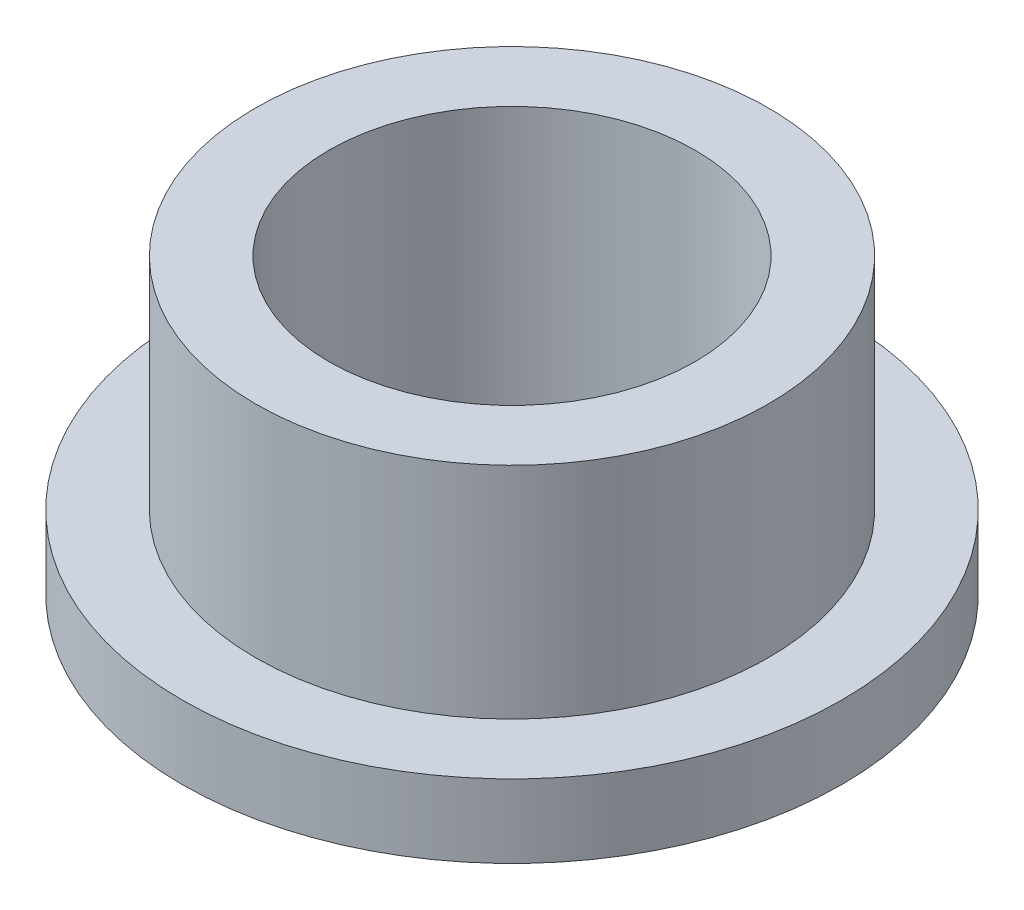
from build123d import *

# Parameters (mm, degrees)
SKETCH1_R           = 9
SKETCH1_R_2         = 5
BOSS_EXTRUDE1_DEPTH = 2
SKETCH2_R           = 7
SKETCH2_R_2         = 5
BOSS_EXTRUDE2_DEPTH = 6


with BuildPart() as part:
    # Sketch1 → Boss-Extrude1 (new body)
    with BuildSketch(Plane(origin=(0, 0, 0), x_dir=(1, 0, 0), z_dir=(0, 1, 0))):
        Circle(SKETCH1_R)
        Circle(SKETCH1_R_2, mode=Mode.SUBTRACT)
    extrude(amount=BOSS_EXTRUDE1_DEPTH)

    # Sketch2 → Boss-Extrude2 (add)
    with BuildSketch(Plane(origin=(0, 2, 0), x_dir=(1, 0, 0), z_dir=(0, 1, 0))):
        Circle(SKETCH2_R)
        Circle(SKETCH2_R_2, mode=Mode.SUBTRACT)
    extrude(amount=BOSS_EXTRUDE2_DEPTH)


solid = part.part
